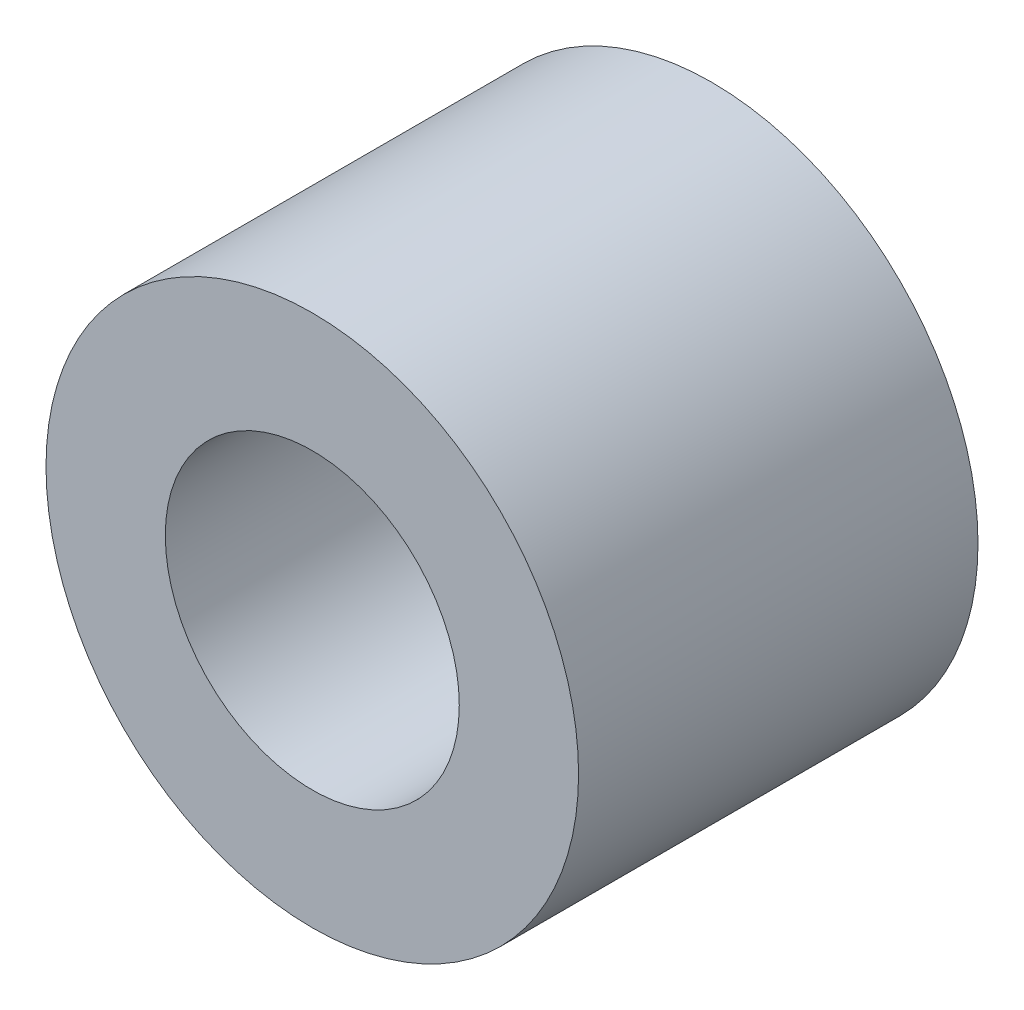
from build123d import *

# Parameters (mm, degrees)
SKETCH3_R      = 3.175
SKETCH3_R_2    = 1.7526
EXTRUDE1_DEPTH = 2.38125


with BuildPart() as part:
    # Sketch3 → Extrude1 (new body, symmetric)
    with BuildSketch(Plane.XY):
        Circle(SKETCH3_R)
        Circle(SKETCH3_R_2, mode=Mode.SUBTRACT)
    extrude(amount=EXTRUDE1_DEPTH, both=True)


solid = part.part
